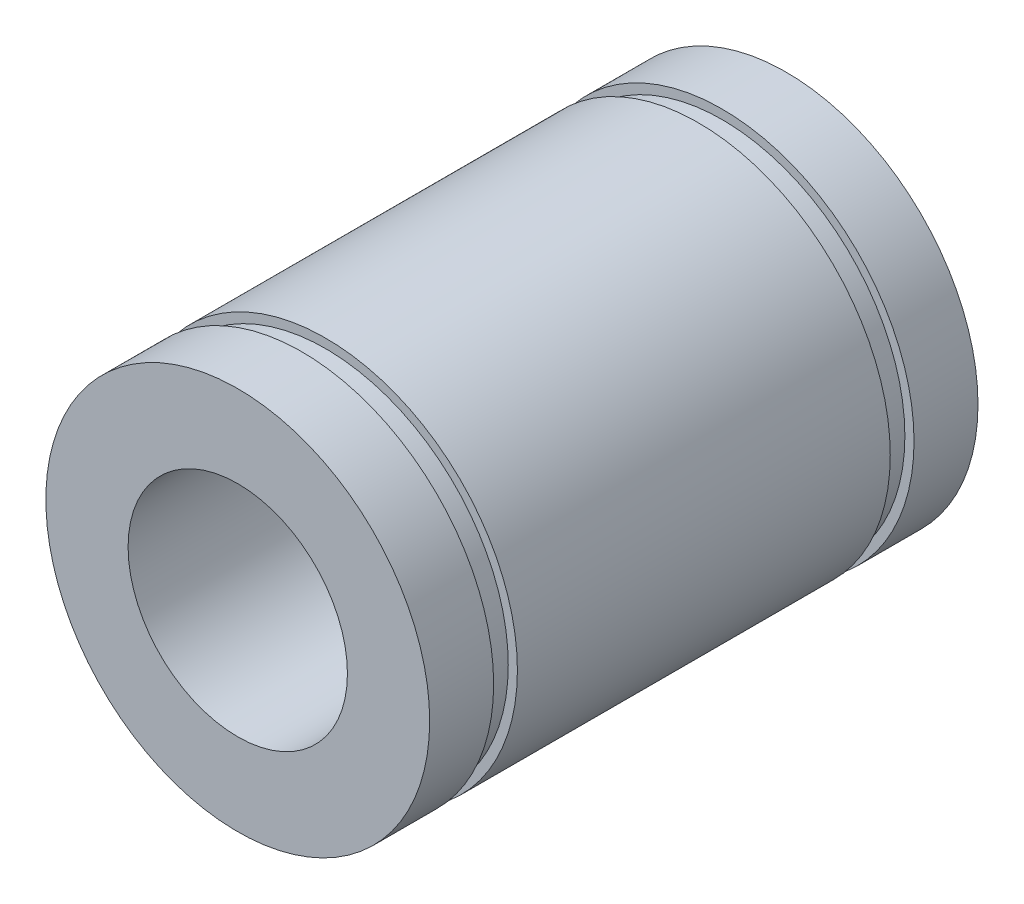
from build123d import *


with BuildPart() as part:
    # Sketch1 → Revolve1 (revolve)
    with BuildSketch(Plane(origin=(0, 0, 0), x_dir=(1, 0, 0), z_dir=(0, 1, 0))):
        Polygon((10.5, 0), (6, 0), (6, -30), (10.5, -30), (10.5, -26.5), (10, -26.5), (10, -25.2), (10.5, -25.2), (10.5, -4.8), (10, -4.8), (10, -3.5), (10.5, -3.5), align=None)
    revolve(axis=Axis((0, 0, 0), (0, 0, 1)))


solid = part.part
